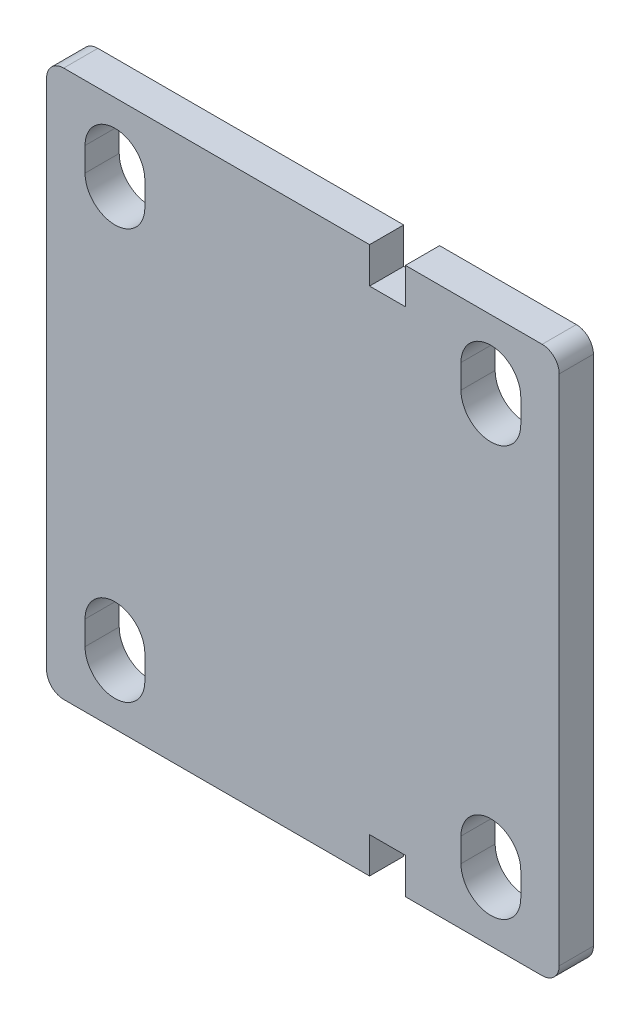
from build123d import *

# Parameters (mm, degrees)
PLAT_W                      = 160
PLAT_H                      = 10
EL_MENT_M_CANO_SOUD_1_DEPTH = 150
D_GAGEMENT_M161_D           = 17.5
D_GAGEMENT_M161_DEPTH       = 10
D_GAGEMENT_M161_TIP         = 5.257530416
ESQUISSE4_W                 = 10.5
ESQUISSE4_H                 = 10.5
ENL_V_MAT_EXTRU_1_DEPTH     = 11
CONG_1_R                    = 5
ENL_V_MAT_EXTRU_2_DEPTH     = 10


with BuildPart() as part:
    # plat → Elément mécano-soudé1 (new body)
    with BuildSketch(Plane.YZ):
        Rectangle(PLAT_W, PLAT_H)
    extrude(amount=EL_MENT_M_CANO_SOUD_1_DEPTH)

    # Dégagement M161
    with Locations(Plane.XY.offset(5)):
        with Locations((130, -60), (130, 60), (20, 60), (20, -60)):
            Hole(D_GAGEMENT_M161_D / 2, depth=D_GAGEMENT_M161_DEPTH)
            with Locations((0, 0, -(D_GAGEMENT_M161_DEPTH + D_GAGEMENT_M161_TIP / 2))):  # 118° drill point
                Cone(0, D_GAGEMENT_M161_D / 2, D_GAGEMENT_M161_TIP, mode=Mode.SUBTRACT)

    # Esquisse4 → Enlèv. mat.-Extru.1 (cut, through all)
    with BuildSketch(Plane.XY.offset(5)):
        with Locations((99.75, 74.75)):
            Rectangle(ESQUISSE4_W, ESQUISSE4_H)
        with Locations((99.75, -74.75)):
            Rectangle(ESQUISSE4_W, ESQUISSE4_H)
    extrude(amount=-ENL_V_MAT_EXTRU_1_DEPTH, mode=Mode.SUBTRACT)

    # Congé1
    cong_1_edges = [part.edges().sort_by_distance(p)[0] for p in [
        (150, 80, 0),
        (150, -80, 0),
        (0, 80, 0),
        (0, -80, 0),
    ]]
    fillet(cong_1_edges, radius=CONG_1_R)

    # Esquisse5 → Enlèv. mat.-Extru.2 (cut)
    with BuildSketch(Plane.XY.offset(5)):
        with BuildLine():
            Line((11.25, 56.5), (11.25, 63.5))
            ThreePointArc((11.25, 63.5), (20, 72.25), (28.75, 63.5))
            Line((28.75, 63.5), (28.75, 56.5))
            ThreePointArc((28.75, 56.5), (20, 47.75), (11.25, 56.5))
        make_face()
        with BuildLine():
            Line((138.75, 56.5), (138.75, 63.5))
            ThreePointArc((138.75, 63.5), (130, 72.25), (121.25, 63.5))
            Line((121.25, 63.5), (121.25, 56.5))
            ThreePointArc((121.25, 56.5), (130, 47.75), (138.75, 56.5))
        make_face()
        with BuildLine():
            Line((138.75, -56.5), (138.75, -63.5))
            ThreePointArc((138.75, -63.5), (130, -72.25), (121.25, -63.5))
            Line((121.25, -63.5), (121.25, -56.5))
            ThreePointArc((121.25, -56.5), (130, -47.75), (138.75, -56.5))
        make_face()
        with BuildLine():
            Line((11.25, -56.5), (11.25, -63.5))
            ThreePointArc((11.25, -63.5), (20, -72.25), (28.75, -63.5))
            Line((28.75, -63.5), (28.75, -56.5))
            ThreePointArc((28.75, -56.5), (20, -47.75), (11.25, -56.5))
        make_face()
    extrude(amount=-ENL_V_MAT_EXTRU_2_DEPTH, mode=Mode.SUBTRACT)


solid = part.part
